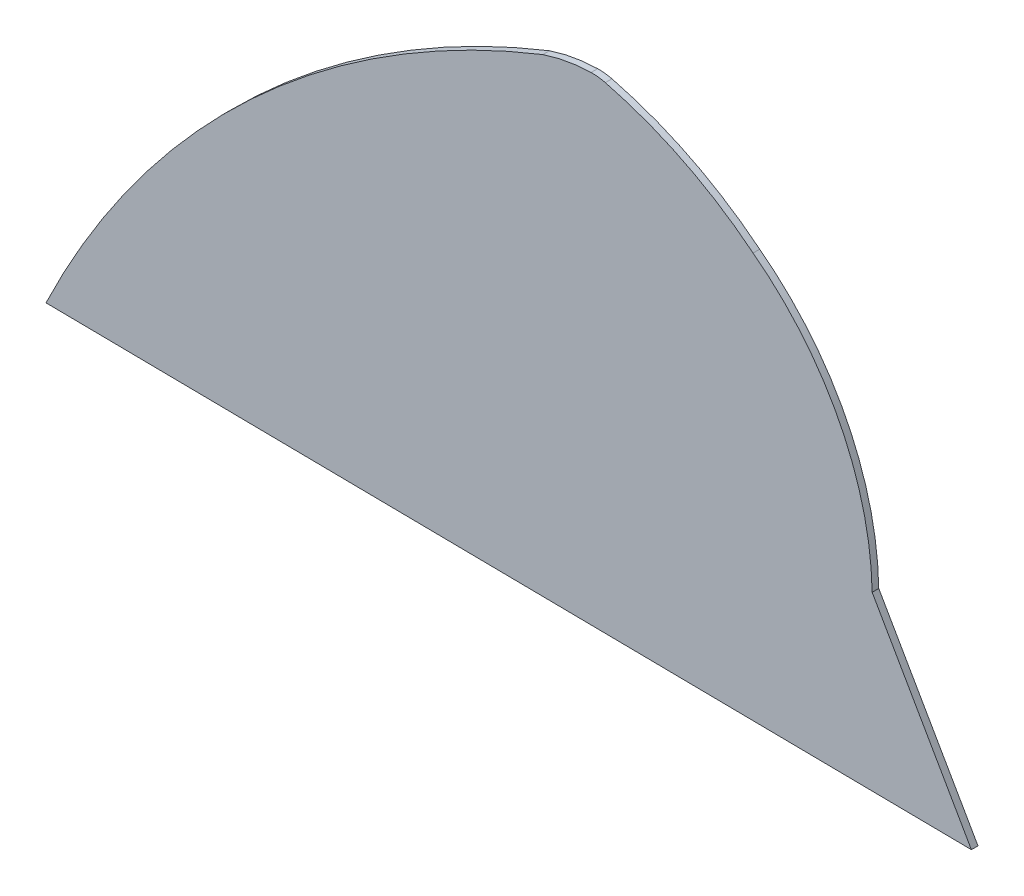
from build123d import *

# Parameters (mm, degrees)
Y_KSEKLIK_EKSTR_ZYON1_DEPTH = 10


with BuildPart() as part:
    # Çizim1 → Yükseklik-Ekstrüzyon1 (new body)
    with BuildSketch(Plane.XY):
        with BuildLine():
            ThreePointArc((15.900247885, 707.260051266), (-426.128478979, 427.588769164), (-735.852954334, 6.072256116))
            Line((-735.852954334, 6.072256116), (664.147045666, -10.43069172))
            Line((664.147045666, -10.43069172), (514.004259651, 251.779036937))
            ThreePointArc((514.004259651, 251.779036937), (464.852209342, 449.785422775), (333.892309545, 606.22057716))
            ThreePointArc((333.892309545, 606.22057716), (228.125604356, 674.012353772), (110.348718239, 717.726493351))
            ThreePointArc((110.348718239, 717.726493351), (99.634050041, 719.676084087), (88.753877168, 720.152379041))
            ThreePointArc((88.753877168, 720.152379041), (51.840168654, 716.457617872), (15.900247885, 707.260051266))
        make_face()
    extrude(amount=Y_KSEKLIK_EKSTR_ZYON1_DEPTH)


solid = part.part
